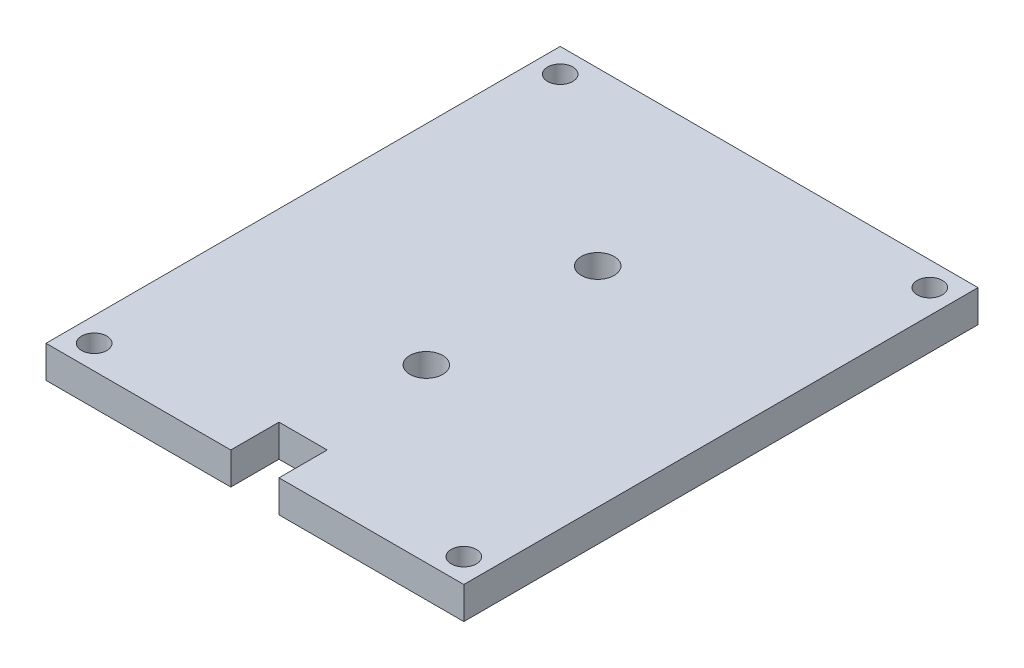
from build123d import *

# Parameters (mm, degrees)
SKETCH1_R           = 2.4892
SKETCH1_R_2         = 3.2512
BOSS_EXTRUDE1_DEPTH = 6.35


with BuildPart() as part:
    # Sketch1 → Boss-Extrude1 (new body)
    with BuildSketch(Plane(origin=(0, 0, 0), x_dir=(1, 0, 0), z_dir=(0, 1, 0))):
        Polygon((-41.275, 46.0375), (41.275, 46.0375), (41.275, -55.5625), (4.7625, -55.5625), (4.7625, -46.0375), (-4.7625, -46.0375), (-4.7625, -55.5625), (-41.275, -55.5625), align=None)
        with Locations((-36.5125, 41.275)):
            Circle(SKETCH1_R, mode=Mode.SUBTRACT)
        with Locations((36.5125, 41.275)):
            Circle(SKETCH1_R, mode=Mode.SUBTRACT)
        with Locations((36.5125, -50.8)):
            Circle(SKETCH1_R, mode=Mode.SUBTRACT)
        with Locations((-36.5125, -50.8)):
            Circle(SKETCH1_R, mode=Mode.SUBTRACT)
        with Locations((0, 12.170833333)):
            Circle(SKETCH1_R_2, mode=Mode.SUBTRACT)
        with Locations((0, -21.695833333)):
            Circle(SKETCH1_R_2, mode=Mode.SUBTRACT)
    extrude(amount=BOSS_EXTRUDE1_DEPTH)


solid = part.part
